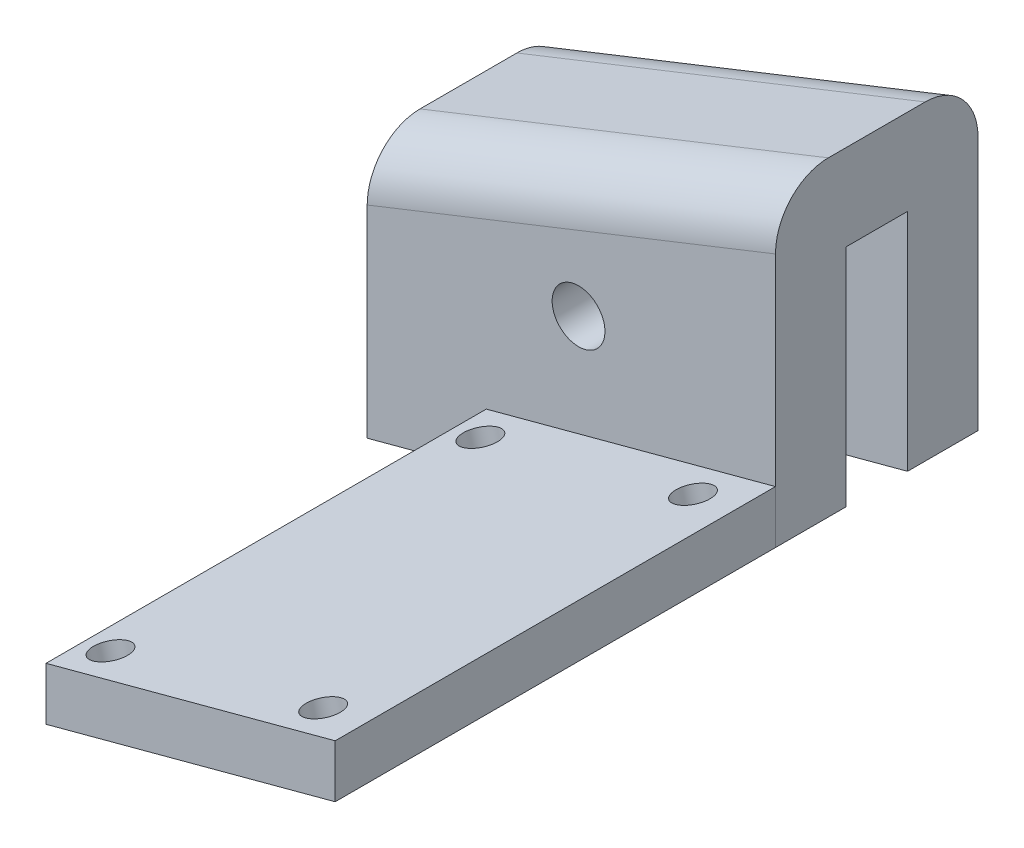
from build123d import *

# Parameters (mm, degrees)
BOSS_EXTRUDE1_DEPTH = 4
BOSS_EXTRUDE2_DEPTH = 25
SKETCH3_R           = 1
CUT_EXTRUDE1_DEPTH  = 34
BOSS_EXTRUDE3_DEPTH = 3.5
BOSS_EXTRUDE4_DEPTH = 4
SKETCH6_R           = 1.5
CUT_EXTRUDE2_DEPTH  = 34
FILLET1_R           = 3


with BuildPart() as part:
    # Sketch1 → Boss-Extrude1 (new body)
    with BuildSketch(Plane.XY):
        Polygon((174.194954223, -57.982184222), (197.377174054, -51.77052714), (197.377174054, -38.986921501), (197.377174054, -34.105402396), (174.194954223, -43.288438949), (174.194954223, -48.347554222), align=None)
    extrude(amount=BOSS_EXTRUDE1_DEPTH)

    # Sketch4 → Boss-Extrude3 (add)
    with BuildSketch(Plane(origin=(0, 0, 0), x_dir=(-1, 0, 0), z_dir=(0, 0, -1))):
        with BuildLine():
            Line((-174.194954223, -43.288438949), (-197.377174054, -34.105402396))
            Line((-197.377174054, -34.105402396), (-197.377174054, -38.986921501))
            add(Edge.make_bspline(
                [(-174.194954249, -48.347554214), (-177.589879135, -47.187067023), (-184.430668648, -44.673129126), (-192.066227253, -41.446744094), (-196.375700505, -39.45835727), (-197.377174056, -38.9869215)],
                knots=[0.498230043, 0.498230043, 0.498230043, 0.498230043, 0.498491185, 0.49876541, 0.498849046, 0.498849046, 0.498849046, 0.498849046], degree=3))
            Line((-174.194954223, -48.347554222), (-174.194954223, -43.288438949))
        make_face()
    extrude(amount=BOSS_EXTRUDE3_DEPTH)

    # Sketch5 → Boss-Extrude4 (add)
    with BuildSketch(Plane(origin=(0, 0, -3.5), x_dir=(-1, 0, 0), z_dir=(0, 0, -1))):
        Polygon((-174.194954223, -43.288438949), (-197.377174054, -34.105402396), (-197.377174054, -51.77052714), (-174.194954223, -57.982184222), align=None)
    extrude(amount=BOSS_EXTRUDE4_DEPTH)

    # Sketch6 → Cut-Extrude2 (cut)
    with BuildSketch(Plane(origin=(0, 0, -7.5), x_dir=(-1, 0, 0), z_dir=(0, 0, -1))):
        with Locations((-186.194954223, -45.982184222)):
            Circle(SKETCH6_R)
    extrude(amount=-CUT_EXTRUDE2_DEPTH, mode=Mode.SUBTRACT)

    # Fillet1
    fillet1_edges = [part.edges().sort_by_distance(p)[0] for p in [
        (185.786064138, -38.696920673, -7.5),
        (185.786064138, -38.696920673, 4),
    ]]
    fillet(fillet1_edges, radius=FILLET1_R)


with BuildPart() as body_2:
    # Sketch2 → Boss-Extrude2 (new body)
    with BuildSketch(Plane.XY.offset(4)):
        Polygon((197.377174054, -51.77052714), (197.377174054, -48.77052714), (180.956435007, -53.170450907), (180.956435007, -56.170450907), align=None)
    extrude(amount=BOSS_EXTRUDE2_DEPTH)

    # Sketch3 → Cut-Extrude1 (cut)
    with BuildSketch(Plane(origin=(26.164395383, -97.646852919, 0), x_dir=(0.9659258262890655, 0.25881904510253134, 0), z_dir=(0.2588190451025313, -0.9659258262890654, 0))):
        with Locations((162.75251154, 6)):
            Circle(SKETCH3_R)
        with Locations((162.75251154, 27)):
            Circle(SKETCH3_R)
        with Locations((175.25251154, 6)):
            Circle(SKETCH3_R)
        with Locations((175.25251154, 27)):
            Circle(SKETCH3_R)
    extrude(amount=-CUT_EXTRUDE1_DEPTH, mode=Mode.SUBTRACT)


solid = Compound([part.part, body_2.part])
